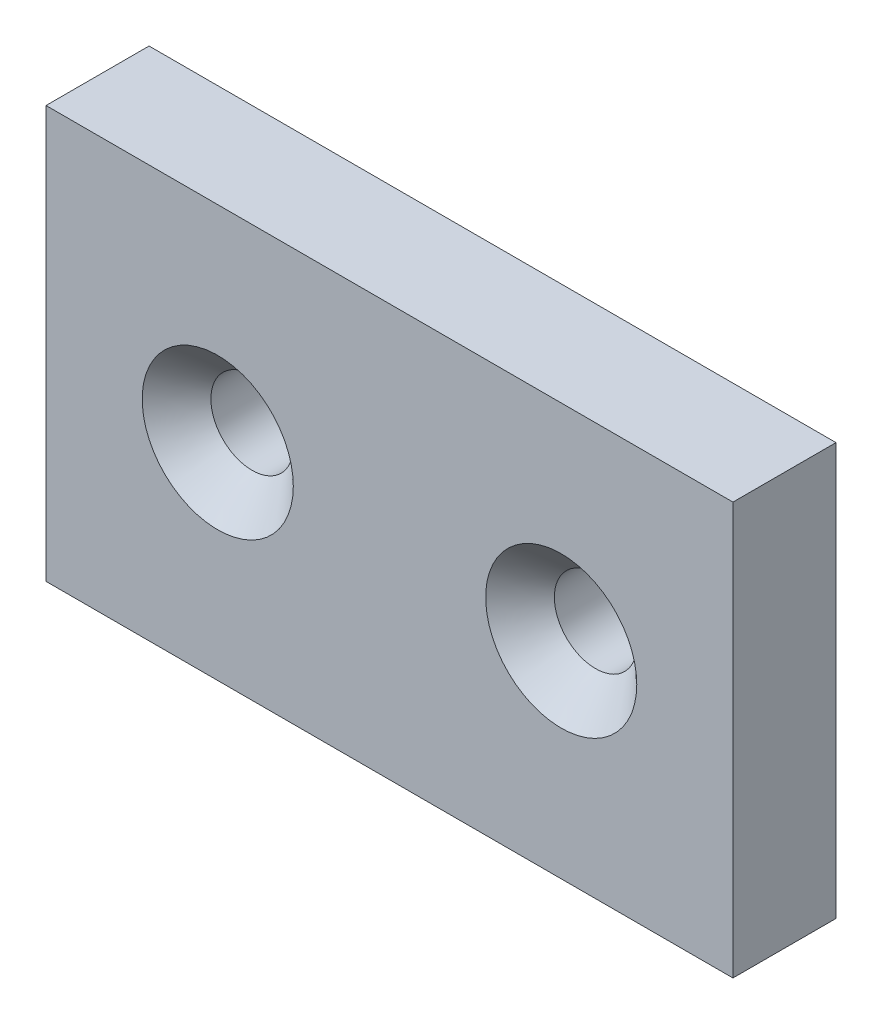
from build123d import *

# Parameters (mm, degrees)
SCHIZZO1_W                             = 20
SCHIZZO1_H                             = 19.7
ESTRUSIONE_ESTRUSIONE1_DEPTH           = 3
FORO_SVASATO_PER_VITE_M2_2_D           = 2.4
FORO_SVASATO_PER_VITE_M2_2_CSINK_D     = 4.4
FORO_SVASATO_PER_VITE_M2_2_CSINK_ANGLE = 90
SCHIZZO7_W                             = 20
SCHIZZO7_H                             = 3.85
TAGLIO_ESTRUSIONE1_DEPTH               = 10


with BuildPart() as part:
    # Schizzo1 → Estrusione-Estrusione1 (new body)
    with BuildSketch(Plane.XY):
        with Locations((10, 9.85)):
            Rectangle(SCHIZZO1_W, SCHIZZO1_H)
    extrude(amount=ESTRUSIONE_ESTRUSIONE1_DEPTH)

    # Foro svasato per Vite M2-2 (through all)
    with Locations(Plane.XY.offset(3)):
        with Locations((5, 9.85), (15, 9.85)):
            CounterSinkHole(FORO_SVASATO_PER_VITE_M2_2_D / 2, FORO_SVASATO_PER_VITE_M2_2_CSINK_D / 2, counter_sink_angle=FORO_SVASATO_PER_VITE_M2_2_CSINK_ANGLE)

    # Schizzo7 → Taglio-Estrusione1 (cut)
    with BuildSketch(Plane(origin=(0, 0, 0), x_dir=(-1, 0, 0), z_dir=(0, 0, -1))):
        with Locations((-10, 17.775)):
            Rectangle(SCHIZZO7_W, SCHIZZO7_H)
        with Locations((-10, 1.925)):
            Rectangle(SCHIZZO7_W, SCHIZZO7_H)
    extrude(amount=-TAGLIO_ESTRUSIONE1_DEPTH, mode=Mode.SUBTRACT)


solid = part.part
